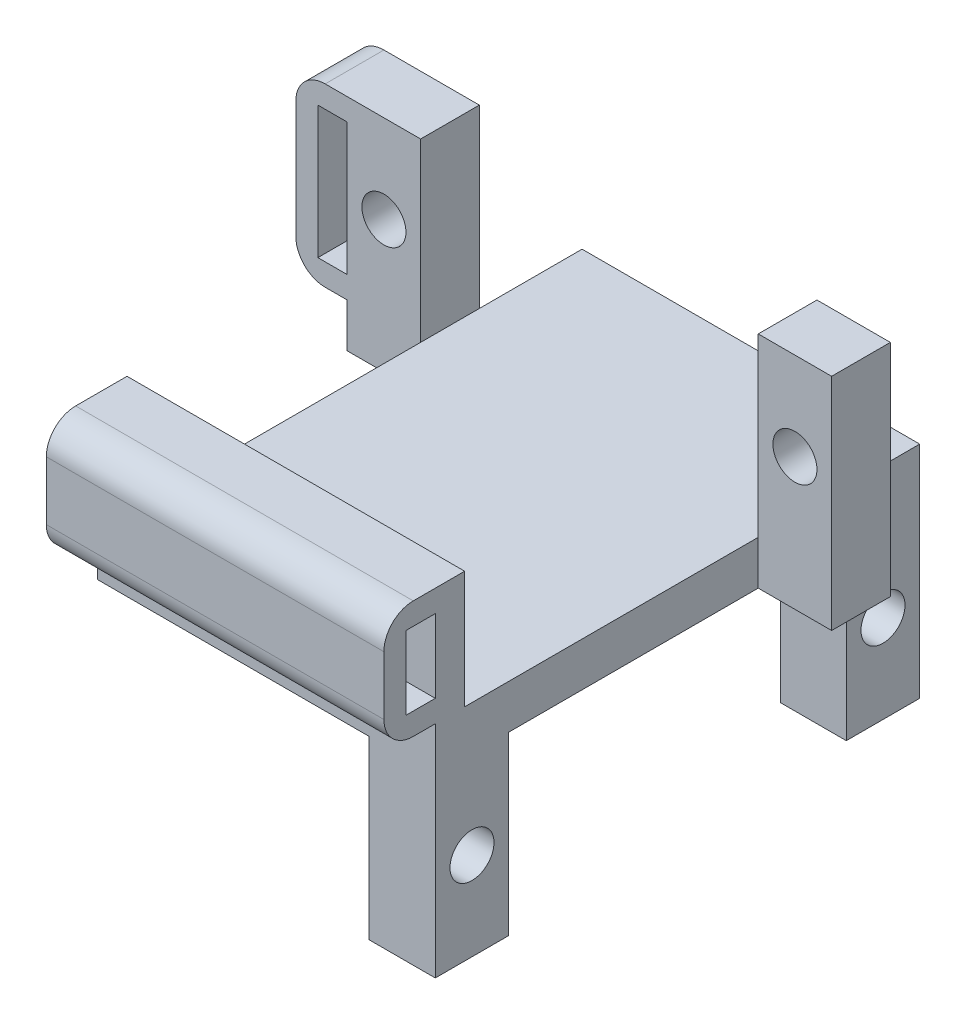
from build123d import *

# Parameters (mm, degrees)
BOSS_EXTRUDE1_DEPTH = 3
SKETCH4_W           = 4.5
SKETCH4_H           = 5
BOSS_EXTRUDE3_DEPTH = 12
SKETCH5_W           = 5
SKETCH5_H           = 4
BOSS_EXTRUDE4_DEPTH = 12
SKETCH6_R           = 1.5
CUT_EXTRUDE1_DEPTH  = 10
SKETCH7_R           = 1.5
CUT_EXTRUDE2_DEPTH  = 10
SKETCH8_W           = 23
SKETCH8_H           = 2
BOSS_EXTRUDE5_DEPTH = 8
SKETCH11_W          = 23
SKETCH11_H          = 8
BOSS_EXTRUDE7_DEPTH = 3.5
SKETCH12_W          = 2
SKETCH12_H          = 5
CUT_EXTRUDE3_DEPTH  = 27.5
FILLET1_R           = 2
SKETCH13_W          = 4
SKETCH13_H          = 12
BOSS_EXTRUDE8_DEPTH = 3.5
SKETCH14_W          = 2
SKETCH14_H          = 9
CUT_EXTRUDE4_DEPTH  = 10
FILLET2_R           = 2


with BuildPart() as part:
    # Sketch1 → Boss-Extrude1 (new body)
    with BuildSketch(Plane(origin=(0, 0, 0), x_dir=(1, 0, 0), z_dir=(0, 1, 0))):
        Polygon((-14.802642583, 11.589093702), (-14.802642583, -10.410906298), (8.197357417, -10.410906298), (8.197357417, 11.589093702), (13.197357417, 11.589093702), (13.197357417, 15.589093702), (8.197357417, 15.589093702), (8.197357417, 22.589093702), (-14.802642583, 22.589093702), (-14.802642583, 15.589093702), (-19.802642583, 15.589093702), (-19.802642583, 11.589093702), align=None)
    extrude(amount=BOSS_EXTRUDE1_DEPTH)

    # Sketch4 → Boss-Extrude3 (add)
    with BuildSketch(Plane.XZ):
        with Locations((5.947357417, -20.089093702)):
            Rectangle(SKETCH4_W, SKETCH4_H)
        with Locations((5.947357417, 7.910906298)):
            Rectangle(SKETCH4_W, SKETCH4_H)
    extrude(amount=BOSS_EXTRUDE3_DEPTH)

    # Sketch5 → Boss-Extrude4 (add)
    with BuildSketch(Plane(origin=(0, 3, 0), x_dir=(1, 0, 0), z_dir=(0, 1, 0))):
        with Locations((-17.302642583, 13.589093702)):
            Rectangle(SKETCH5_W, SKETCH5_H)
        with Locations((10.697357417, 13.589093702)):
            Rectangle(SKETCH5_W, SKETCH5_H)
    extrude(amount=BOSS_EXTRUDE4_DEPTH)

    # Sketch6 → Cut-Extrude1 (cut)
    with BuildSketch(Plane.XY.offset(-11.589093702)):
        with Locations((-17.302642583, 9)):
            Circle(SKETCH6_R)
        with Locations((10.697357417, 9)):
            Circle(SKETCH6_R)
    extrude(amount=-CUT_EXTRUDE1_DEPTH, mode=Mode.SUBTRACT)

    # Sketch7 → Cut-Extrude2 (cut)
    with BuildSketch(Plane(origin=(8.197357417, 0, 0), x_dir=(0, 0, -1), z_dir=(1, 0, 0))):
        with Locations((-7.910906298, -6)):
            Circle(SKETCH7_R)
        with Locations((20.089093702, -6)):
            Circle(SKETCH7_R)
    extrude(amount=-CUT_EXTRUDE2_DEPTH, mode=Mode.SUBTRACT)

    # Sketch8 → Boss-Extrude5 (add)
    with BuildSketch(Plane(origin=(0, 3, 0), x_dir=(1, 0, 0), z_dir=(0, 1, 0))):
        with Locations((-3.302642583, -9.410906298)):
            Rectangle(SKETCH8_W, SKETCH8_H)
    extrude(amount=BOSS_EXTRUDE5_DEPTH)

    # Sketch11 → Boss-Extrude7 (add)
    with BuildSketch(Plane.XY.offset(10.410906298)):
        with Locations((-3.302642583, 7)):
            Rectangle(SKETCH11_W, SKETCH11_H)
    extrude(amount=BOSS_EXTRUDE7_DEPTH)

    # Sketch12 → Cut-Extrude3 (cut)
    with BuildSketch(Plane.ZY.offset(14.802642583)):
        with Locations((11.410906298, 7)):
            Rectangle(SKETCH12_W, SKETCH12_H)
    extrude(amount=-CUT_EXTRUDE3_DEPTH, mode=Mode.SUBTRACT)

    # Fillet1
    fillet1_edges = [part.edges().sort_by_distance(p)[0] for p in [
        (-3.302642583, 3, 13.910906298),
        (-3.302642583, 11, 13.910906298),
    ]]
    fillet(fillet1_edges, radius=FILLET1_R)

    # Sketch13 → Boss-Extrude8 (add)
    with BuildSketch(Plane.ZY.offset(19.802642583)):
        with Locations((-13.589093702, 9)):
            Rectangle(SKETCH13_W, SKETCH13_H)
    extrude(amount=BOSS_EXTRUDE8_DEPTH)

    # Sketch14 → Cut-Extrude4 (cut)
    with BuildSketch(Plane.XY.offset(-11.589093702)):
        with Locations((-20.802642583, 9)):
            Rectangle(SKETCH14_W, SKETCH14_H)
    extrude(amount=-CUT_EXTRUDE4_DEPTH, mode=Mode.SUBTRACT)

    # Fillet2
    fillet2_edges = [part.edges().sort_by_distance(p)[0] for p in [
        (-23.302642583, 3, -13.589093702),
        (-23.302642583, 15, -13.589093702),
    ]]
    fillet(fillet2_edges, radius=FILLET2_R)


solid = part.part
